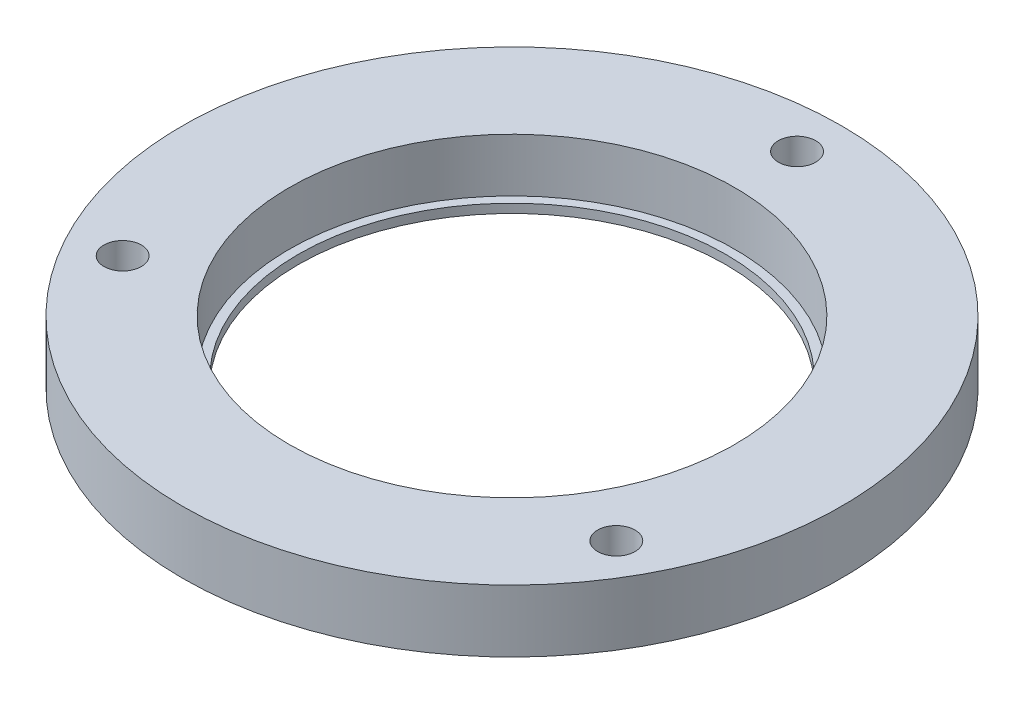
from build123d import *

# Parameters (mm, degrees)
SKETCH1_R           = 37
BOSS_EXTRUDE1_DEPTH = 6
SKETCH2_R           = 2.1
CUT_EXTRUDE1_DEPTH  = 7
CIRPATTERN1_COUNT   = 3
SKETCH3_R           = 25
CUT_EXTRUDE2_DEPTH  = 7
SKETCH4_R           = 37
SKETCH4_R_2         = 24
SKETCH4_R_3         = 2.1
BOSS_EXTRUDE2_DEPTH = 1


with BuildPart() as part:
    # Sketch1 → Boss-Extrude1 (new body)
    with BuildSketch(Plane(origin=(0, 0, 0), x_dir=(1, 0, 0), z_dir=(0, 1, 0))):
        Circle(SKETCH1_R)
    extrude(amount=BOSS_EXTRUDE1_DEPTH)

    # Sketch2 → Cut-Extrude1 (cut, through all)
    with BuildSketch(Plane(origin=(0, 6, 0), x_dir=(1, 0, 0), z_dir=(0, 1, 0))):
        with Locations((0, 32)):
            Circle(SKETCH2_R)
    cut_extrude1 = extrude(amount=-CUT_EXTRUDE1_DEPTH, mode=Mode.SUBTRACT)

    # CirPattern1: Cut-Extrude1 ×3 about axis
    cirpattern1_axis = Axis((0, 0, 0), (0, 1, 0))
    for i in range(1, CIRPATTERN1_COUNT):
        add(cut_extrude1.rotate(cirpattern1_axis, i * 360 / CIRPATTERN1_COUNT), mode=Mode.SUBTRACT)

    # Sketch3 → Cut-Extrude2 (cut, through all)
    with BuildSketch(Plane(origin=(0, 6, 0), x_dir=(1, 0, 0), z_dir=(0, 1, 0))):
        Circle(SKETCH3_R)
    extrude(amount=-CUT_EXTRUDE2_DEPTH, mode=Mode.SUBTRACT)

    # Sketch4 → Boss-Extrude2 (add)
    with BuildSketch(Plane(origin=(0, 0, 0), x_dir=(1, 0, 0), z_dir=(0, 1, 0))):
        Circle(SKETCH4_R)
        Circle(SKETCH4_R_2, mode=Mode.SUBTRACT)
        with Locations((-27.712812921, -16)):
            Circle(SKETCH4_R_3, mode=Mode.SUBTRACT)
        with Locations((27.712812921, -16)):
            Circle(SKETCH4_R_3, mode=Mode.SUBTRACT)
        with Locations((0, 32)):
            Circle(SKETCH4_R_3, mode=Mode.SUBTRACT)
    extrude(amount=-BOSS_EXTRUDE2_DEPTH)


solid = part.part
